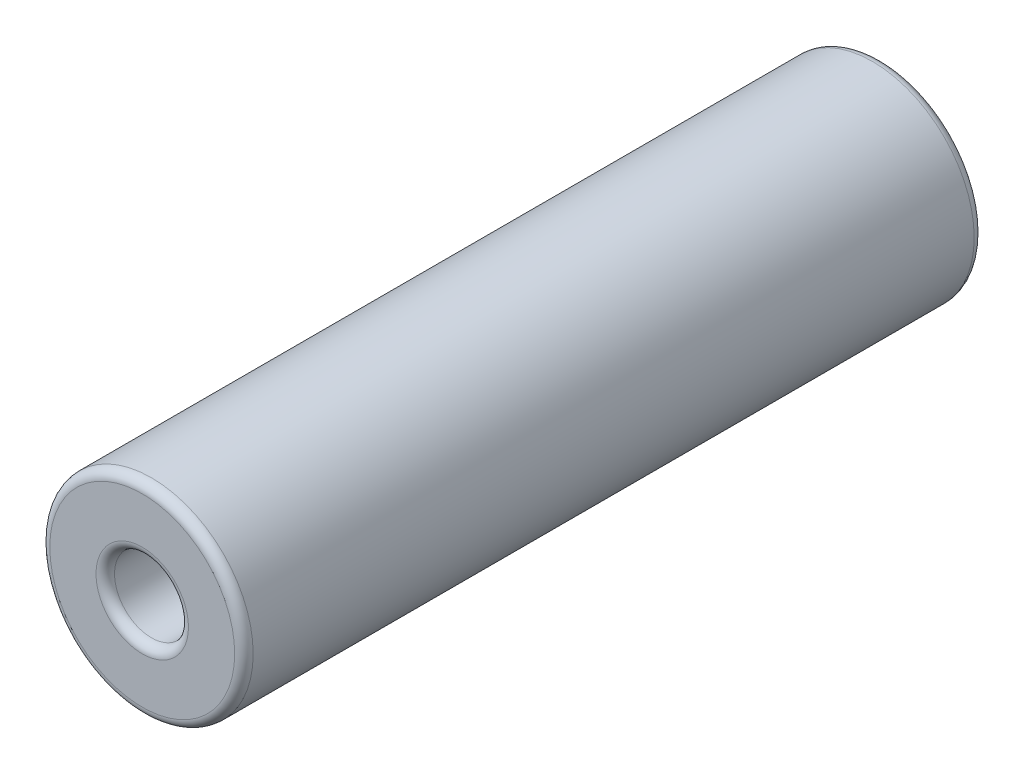
from build123d import *

# Parameters (mm, degrees)
SKETCH1_R           = 5.5
BOSS_EXTRUDE1_DEPTH = 40
SKETCH2_R           = 2
CUT_EXTRUDE1_DEPTH  = 41
FILLET1_R           = 0.5


with BuildPart() as part:
    # Sketch1 → Boss-Extrude1 (new body)
    with BuildSketch(Plane.XY):
        Circle(SKETCH1_R)
    extrude(amount=BOSS_EXTRUDE1_DEPTH)

    # Sketch2 → Cut-Extrude1 (cut, through all)
    with BuildSketch(Plane.XY.offset(40)):
        Circle(SKETCH2_R)
    extrude(amount=-CUT_EXTRUDE1_DEPTH, mode=Mode.SUBTRACT)

    # Fillet1
    fillet1_edges = [part.edges().sort_by_distance(p)[0] for p in [
        (-5.5, 0, 0),
        (-5.5, 0, 40),
        (-2, 0, 0),
        (-2, 0, 40),
    ]]
    fillet(fillet1_edges, radius=FILLET1_R)


solid = part.part
